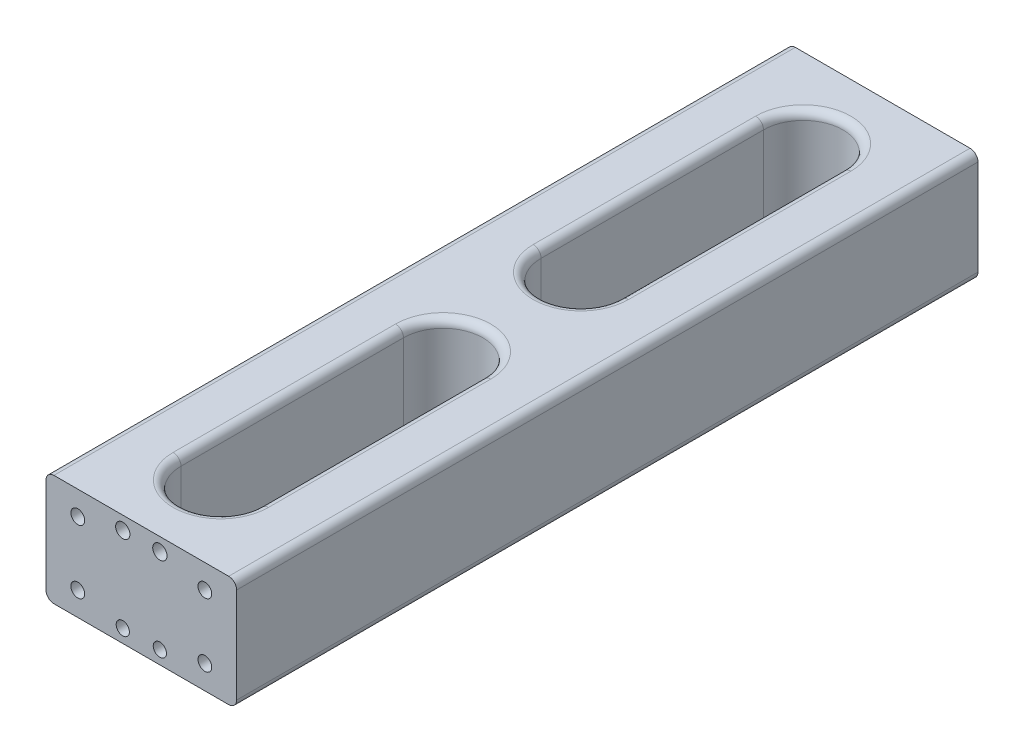
from build123d import *

# Parameters (mm, degrees)
SKETCH_1_W          = 36
SKETCH_1_H          = 21
SKETCH_1_R          = 1.25
SKETCH_1_R_2        = 1.3
SKETCH_1_R_3        = 1.35
EXTRUDE_1_DEPTH     = 140
SKETCH_1_5_R        = 1.3
SKETCH_1_5_R_2      = 1.35
SKETCH_1_5_R_3      = 1.25
CUT_EXTRUDE_1_DEPTH = 4
CUT_EXTRUDE_START   = 140
SKETCH_1_6_R        = 1.35
SKETCH_1_6_R_2      = 1.3
SKETCH_1_6_R_3      = 1.25
CUT_EXTRUDE_2_DEPTH = 4
CUT_EXTRUDE_3_REACH = 144.706
FILLET_1_R          = 1.5


with BuildPart() as part:
    # 스케치1 → 보스-돌출1 (new body)
    with BuildSketch(Plane.XY):
        Rectangle(SKETCH_1_W, SKETCH_1_H)
        with Locations((-3.5, -8)):
            Circle(SKETCH_1_R, mode=Mode.SUBTRACT)
        with Locations((3.5, -8)):
            Circle(SKETCH_1_R, mode=Mode.SUBTRACT)
        with Locations((-12, 6)):
            Circle(SKETCH_1_R_2, mode=Mode.SUBTRACT)
        with Locations((12, 6)):
            Circle(SKETCH_1_R_2, mode=Mode.SUBTRACT)
        with Locations((12, -6)):
            Circle(SKETCH_1_R_2, mode=Mode.SUBTRACT)
        with Locations((-12, -6)):
            Circle(SKETCH_1_R_2, mode=Mode.SUBTRACT)
        with Locations((3.5, 8)):
            Circle(SKETCH_1_R_3, mode=Mode.SUBTRACT)
        with Locations((-3.5, 8)):
            Circle(SKETCH_1_R_3, mode=Mode.SUBTRACT)
        with Locations((12, -6)):
            Circle(SKETCH_1_R_2)
        with Locations((3.5, -8)):
            Circle(SKETCH_1_R)
        with Locations((-3.5, -8)):
            Circle(SKETCH_1_R)
        with Locations((-12, -6)):
            Circle(SKETCH_1_R_2)
        with Locations((-12, 6)):
            Circle(SKETCH_1_R_2)
        with Locations((-3.5, 8)):
            Circle(SKETCH_1_R_3)
        with Locations((3.5, 8)):
            Circle(SKETCH_1_R_3)
        with Locations((12, 6)):
            Circle(SKETCH_1_R_2)
    extrude(amount=EXTRUDE_1_DEPTH)

    # 스케치1<5> → 컷-돌출1 (cut)
    with BuildSketch(Plane.XY):
        with Locations((12, 6)):
            Circle(SKETCH_1_5_R)
        with Locations((3.5, 8)):
            Circle(SKETCH_1_5_R_2)
        with Locations((-3.5, 8)):
            Circle(SKETCH_1_5_R_2)
        with Locations((-12, 6)):
            Circle(SKETCH_1_5_R)
        with Locations((-12, -6)):
            Circle(SKETCH_1_5_R)
        with Locations(Location((-3.5, -8, 0), (0, 0, 180))):
            Circle(SKETCH_1_5_R_3)
        with Locations((3.5, -8)):
            Circle(SKETCH_1_5_R_3)
        with Locations((12, -6)):
            Circle(SKETCH_1_5_R)
    extrude(amount=CUT_EXTRUDE_1_DEPTH, mode=Mode.SUBTRACT)

    # 스케치1<6> → 컷-돌출2 (cut)
    with BuildSketch(Plane.XY.offset(CUT_EXTRUDE_START)):
        with Locations((3.5, 8)):
            Circle(SKETCH_1_6_R)
        with Locations((12, 6)):
            Circle(SKETCH_1_6_R_2)
        with Locations((-3.5, 8)):
            Circle(SKETCH_1_6_R)
        with Locations((-12, 6)):
            Circle(SKETCH_1_6_R_2)
        with Locations((-12, -6)):
            Circle(SKETCH_1_6_R_2)
        with Locations(Location((-3.5, -8, 0), (0, 0, 180))):
            Circle(SKETCH_1_6_R_3)
        with Locations((3.5, -8)):
            Circle(SKETCH_1_6_R_3)
        with Locations((12, -6)):
            Circle(SKETCH_1_6_R_2)
    extrude(amount=-CUT_EXTRUDE_2_DEPTH, mode=Mode.SUBTRACT)

    # 스케치2 → 컷-돌출3 (cut, up to next)
    with BuildSketch(Plane(origin=(0, 10.5, 0), x_dir=(1, 0, 0), z_dir=(0, 1, 0)), mode=Mode.PRIVATE) as cut_extrude_3_sk1:
        with BuildLine():
            Line((7.5, -15), (7.5, -57))
            ThreePointArc((7.5, -57), (0, -64.5), (-7.5, -57))
            Line((-7.5, -57), (-7.5, -15))
            ThreePointArc((-7.5, -15), (0, -7.5), (7.5, -15))
        make_face()
    cut_extrude_3_tool1 = extrude(cut_extrude_3_sk1.sketch, amount=-CUT_EXTRUDE_3_REACH, mode=Mode.PRIVATE) & part.part
    # 스케치2 → 컷-돌출3 (cut, up to next)
    with BuildSketch(Plane(origin=(0, 10.5, 0), x_dir=(1, 0, 0), z_dir=(0, 1, 0)), mode=Mode.PRIVATE) as cut_extrude_3_sk2:
        with BuildLine():
            Line((7.5, -125), (7.5, -83))
            ThreePointArc((7.5, -83), (0, -75.5), (-7.5, -83))
            Line((-7.5, -83), (-7.5, -125))
            ThreePointArc((-7.5, -125), (0, -132.5), (7.5, -125))
        make_face()
    cut_extrude_3_tool2 = extrude(cut_extrude_3_sk2.sketch, amount=-CUT_EXTRUDE_3_REACH, mode=Mode.PRIVATE) & part.part
    add(cut_extrude_3_tool1.solids().sort_by_distance((0, 10.5, 36))[0], mode=Mode.SUBTRACT)
    add(cut_extrude_3_tool2.solids().sort_by_distance((0, 10.5, 104))[0], mode=Mode.SUBTRACT)

    # 필렛1
    fillet_1_edges = [part.edges().sort_by_distance(p)[0] for p in [
        (0, -10.5, 7.5),
        (7.5, -10.5, 36),
        (0, -10.5, 64.5),
        (-7.5, -10.5, 36),
        (0, 10.5, 7.5),
        (-18, 10.5, 70),
        (-7.5, 10.5, 36),
        (0, 10.5, 64.5),
        (7.5, 10.5, 36),
        (18, 10.5, 70),
        (18, -10.5, 70),
        (-18, -10.5, 70),
        (0, -10.5, 132.5),
        (-7.5, -10.5, 104),
        (0, -10.5, 75.5),
        (7.5, -10.5, 104),
        (0, 10.5, 132.5),
        (7.5, 10.5, 104),
        (0, 10.5, 75.5),
        (-7.5, 10.5, 104),
    ]]
    fillet(fillet_1_edges, radius=FILLET_1_R)


solid = part.part
